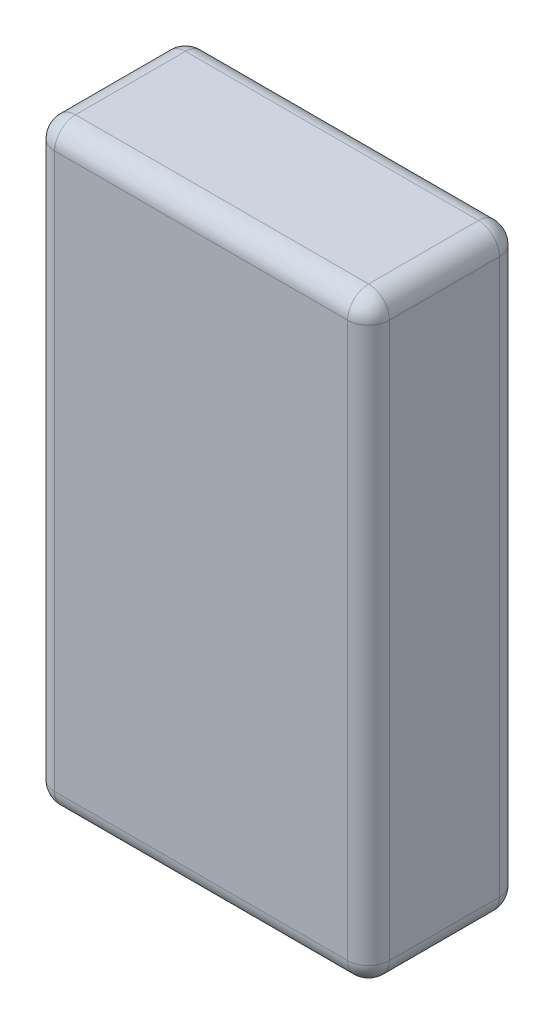
from build123d import *

# Parameters (mm, degrees)
SKETCH1_W           = 32
SKETCH1_H           = 14.5
BOSS_EXTRUDE1_DEPTH = 57
FILLET1_R           = 2


with BuildPart() as part:
    # Sketch1 → Boss-Extrude1 (new body)
    with BuildSketch(Plane(origin=(0, 0, 0), x_dir=(1, 0, 0), z_dir=(0, 1, 0))):
        with Locations((16, 7.25)):
            Rectangle(SKETCH1_W, SKETCH1_H)
    extrude(amount=BOSS_EXTRUDE1_DEPTH)

    # Fillet1
    fillet1_edges = [part.edges().sort_by_distance(p)[0] for p in [
        (32, 57, -7.25),
        (16, 57, -14.5),
        (0, 57, -7.25),
        (16, 0, -14.5),
        (32, 0, -7.25),
        (16, 0, 0),
        (0, 0, -7.25),
        (0, 28.5, -14.5),
        (32, 28.5, -14.5),
        (32, 28.5, 0),
        (0, 28.5, 0),
        (16, 57, 0),
    ]]
    fillet(fillet1_edges, radius=FILLET1_R)


solid = part.part
